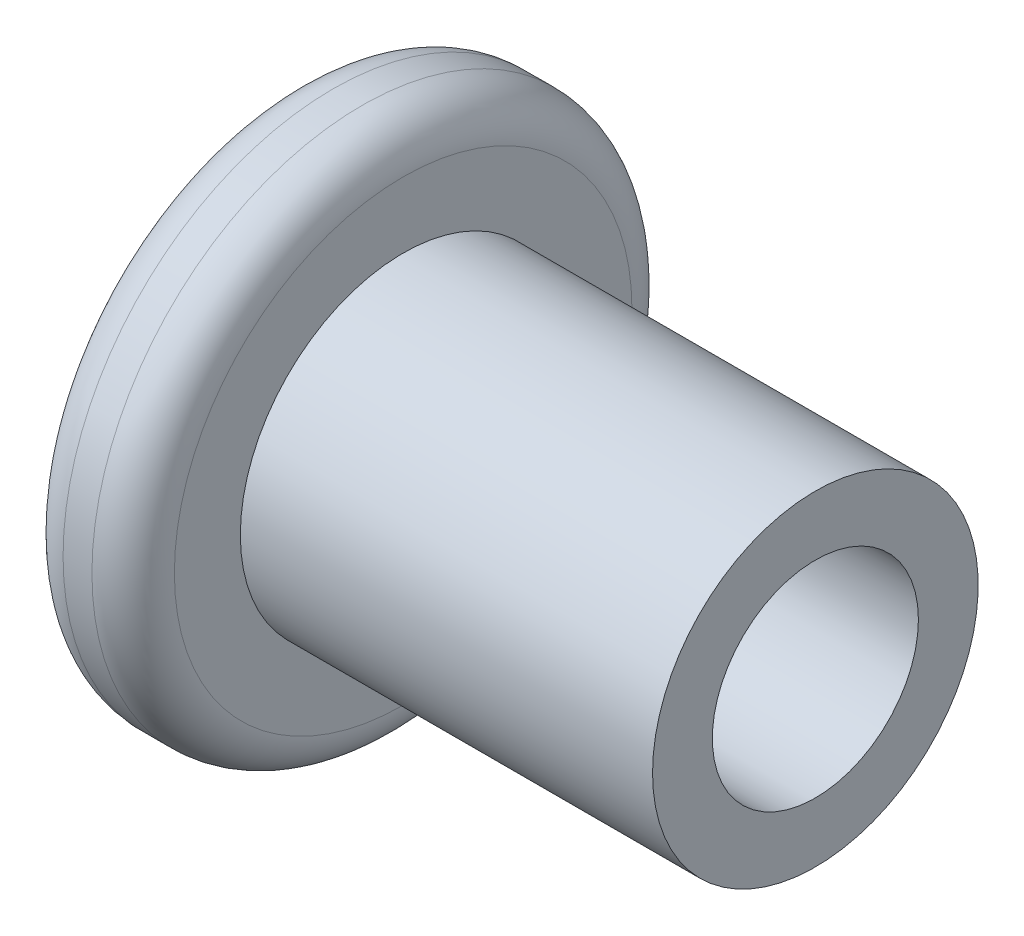
from build123d import *

# Parameters (mm, degrees)
FILLET_1_R             = 1
CUT_EXTRUDE_1_DEPTH    = 1
HOLE_WIZARD_M6_1_D     = 5
HOLE_WIZARD_M6_1_DEPTH = 4.1
HOLE_WIZARD_M6_1_TIP   = 1.502151548


with BuildPart() as part:
    # 草图1 → 旋转1 (revolve)
    with BuildSketch(Plane.XY):
        Polygon((0, 0), (0, 6.55), (2.7, 6.55), (2.7, 3.95), (12.7, 3.95), (12.7, 0), align=None)
    revolve(axis=Axis((0, 0, 0), (1, 0, 0)))

    # 圆角1
    fillet_1_edges = [part.edges().sort_by_distance(p)[0] for p in [
        (2.7, -6.55, 0),
        (0, -6.55, 0),
    ]]
    fillet(fillet_1_edges, radius=FILLET_1_R)

    # 草图2 → 切除-拉伸1 (cut)
    with BuildSketch(Plane.ZY):
        Polygon((1.154700538, 2), (-1.154700538, 2), (-2.309401077, 0), (-1.154700538, -2), (1.154700538, -2), (2.309401077, 0), align=None)
    extrude(amount=-CUT_EXTRUDE_1_DEPTH, mode=Mode.SUBTRACT)

    # M6 螺纹孔1
    with Locations(Plane(origin=(12.7, 0, 0), x_dir=(0, 0, -1), z_dir=(1, 0, 0))):
        with Locations((0, 0)):
            Hole(HOLE_WIZARD_M6_1_D / 2, depth=HOLE_WIZARD_M6_1_DEPTH)
            with Locations((0, 0, -(HOLE_WIZARD_M6_1_DEPTH + HOLE_WIZARD_M6_1_TIP / 2))):  # 118° drill point
                Cone(0, HOLE_WIZARD_M6_1_D / 2, HOLE_WIZARD_M6_1_TIP, mode=Mode.SUBTRACT)


solid = part.part
